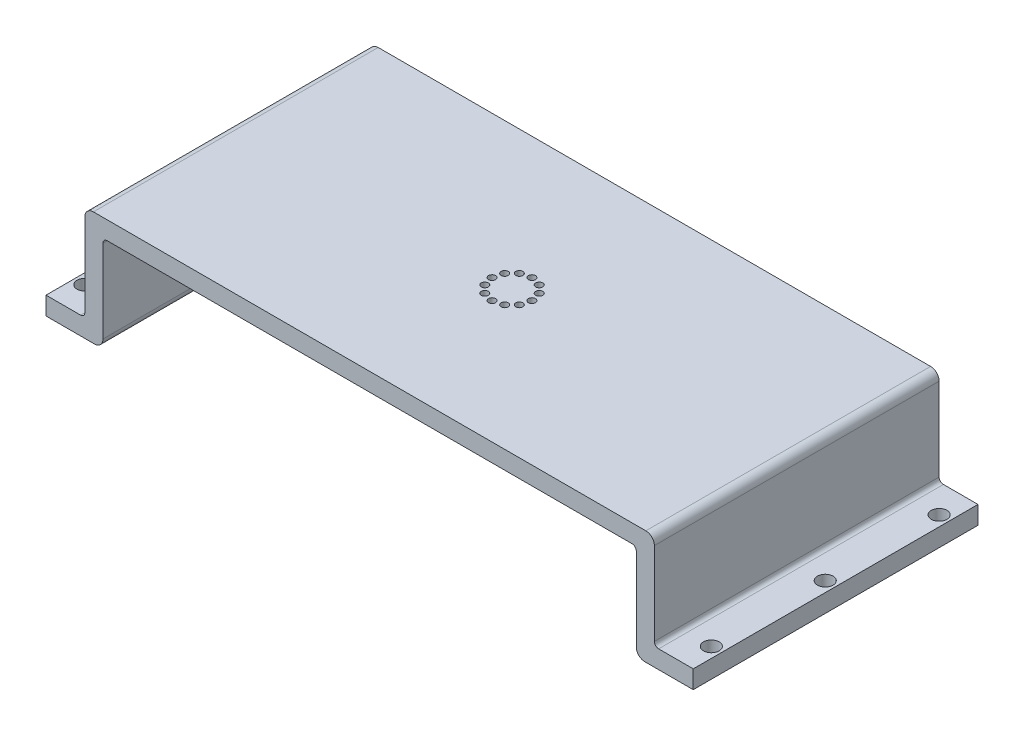
from build123d import *
from OCP.BRepFilletAPI import BRepFilletAPI_MakeFillet

# Parameters (mm, degrees)
BOSS_EXTRUDE1_DEPTH            = 100
FILLET1_R1                     = 3
FILLET1_R2                     = 1.5
F_2_5MM_DOWEL_HOLE1_AT_2_COUNT = 2
F_2_5MM_DOWEL_HOLE1_AT_2_PITCH = 14
CIRPATTERN3_COUNT              = 6
CIRPATTERN3_ANGLE              = 150
F_5_5_5_5_DIAMETER_HOLE1_D     = 5.5


with BuildPart() as part:
    # Sketch1 → Boss-Extrude1 (new body)
    with BuildSketch(Plane.XY):
        Polygon((100, 0), (-100, 0), (-100, -33.65), (-113.65, -33.65), (-113.65, -40), (-93.65, -40), (-93.65, -6.35), (93.65, -6.35), (93.65, -40), (113.65, -40), (113.65, -33.65), (100, -33.65), align=None)
    extrude(amount=BOSS_EXTRUDE1_DEPTH)

    # Fillet1: one fillet with a radius per group of edges: ONE call of the kernel's fillet builder (fillet() takes one radius for all edges)
    fillet1_edges_1 = [part.edges().sort_by_distance(p)[0] for p in [
        (-100, 0, 50),
        (-93.65, -40, 50),
        (100, 0, 50),
        (93.65, -40, 50),
    ]]
    fillet1_edges_2 = [part.edges().sort_by_distance(p)[0] for p in [
        (-93.65, -6.35, 50),
        (93.65, -6.35, 50),
        (100, -33.65, 50),
        (-100, -33.65, 50),
    ]]
    fillet1 = BRepFilletAPI_MakeFillet(part.part.solid().wrapped)
    for e in fillet1_edges_1:
        fillet1.Add(FILLET1_R1, e.wrapped)
    for e in fillet1_edges_2:
        fillet1.Add(FILLET1_R2, e.wrapped)
    add(Compound.cast(fillet1.Shape()), mode=Mode.REPLACE)

    # Sketch2 → Ø2.5mm Dowel Hole1 (revolve, cut)
    with BuildSketch(Plane(origin=(0, -6.35, 57), x_dir=(0, 0, -1), z_dir=(1, 0, 0))):
        Polygon((0, 0), (0, 10.751075774), (1.25, 10), (1.25, 0), align=None)
    f_2_5mm_dowel_hole1 = revolve(axis=Axis((0, -12.7, 57), (0, 1, 0)), mode=Mode.SUBTRACT)

    # Ø2.5mm Dowel Hole1 at 2: Ø2.5mm Dowel Hole1 ×2
    with Locations(*[(0, 0, -i * F_2_5MM_DOWEL_HOLE1_AT_2_PITCH) for i in range(1, F_2_5MM_DOWEL_HOLE1_AT_2_COUNT)]):
        add(f_2_5mm_dowel_hole1, mode=Mode.SUBTRACT)

    # CirPattern3: Ø2.5mm Dowel Hole1 ×6 about axis
    cirpattern3_axis = Axis((0, -6.35, 50), (0, -1, 0))
    for i in range(1, CIRPATTERN3_COUNT):
        add(f_2_5mm_dowel_hole1.rotate(cirpattern3_axis, i * CIRPATTERN3_ANGLE / (CIRPATTERN3_COUNT - 1)), mode=Mode.SUBTRACT)

    # CirPattern3 copy 1 sketch → CirPattern3 copy 1 (revolve, cut)
    with BuildSketch(Plane(origin=(3.5, -6.35, 43.937822174), x_dir=(0.500000000000001, 0, -0.866025403784438), z_dir=(0.866025403784438, 0, 0.500000000000001))):
        Polygon((0, 0), (0, 10.751075774), (1.25, 10), (1.25, 0), align=None)
    revolve(axis=Axis((3.5, -12.7, 43.937822174), (0, 1, 0)), mode=Mode.SUBTRACT)

    # CirPattern3 copy 2 sketch → CirPattern3 copy 2 (revolve, cut)
    with BuildSketch(Plane(origin=(6.062177826, -6.35, 46.5), x_dir=(0.8660254037844398, 0, -0.499999999999998), z_dir=(0.499999999999998, 0, 0.8660254037844398))):
        Polygon((0, 0), (0, 10.751075774), (1.25, 10), (1.25, 0), align=None)
    revolve(axis=Axis((6.062177826, -12.7, 46.5), (0, 1, 0)), mode=Mode.SUBTRACT)

    # CirPattern3 copy 3 sketch → CirPattern3 copy 3 (revolve, cut)
    with BuildSketch(Plane(origin=(7, -6.35, 50), x_dir=(1, 0, 0), z_dir=(0, 0, 1))):
        Polygon((0, 0), (0, 10.751075774), (1.25, 10), (1.25, 0), align=None)
    revolve(axis=Axis((7, -12.7, 50), (0, 1, 0)), mode=Mode.SUBTRACT)

    # CirPattern3 copy 4 sketch → CirPattern3 copy 4 (revolve, cut)
    with BuildSketch(Plane(origin=(6.062177826, -6.35, 53.5), x_dir=(0.8660254037844363, 0, 0.500000000000004), z_dir=(-0.500000000000004, 0, 0.8660254037844363))):
        Polygon((0, 0), (0, 10.751075774), (1.25, 10), (1.25, 0), align=None)
    revolve(axis=Axis((6.062177826, -12.7, 53.5), (0, 1, 0)), mode=Mode.SUBTRACT)

    # CirPattern3 copy 5 sketch → CirPattern3 copy 5 (revolve, cut)
    with BuildSketch(Plane(origin=(3.5, -6.35, 56.062177826), x_dir=(0.49999999999999495, 0, 0.8660254037844416), z_dir=(-0.8660254037844416, 0, 0.49999999999999495))):
        Polygon((0, 0), (0, 10.751075774), (1.25, 10), (1.25, 0), align=None)
    revolve(axis=Axis((3.5, -12.7, 56.062177826), (0, 1, 0)), mode=Mode.SUBTRACT)

    # Ø5.5 (5.5) Diameter Hole1 (through all)
    with Locations(Plane(origin=(0, -33.65, 0), x_dir=(1, 0, 0), z_dir=(0, 1, 0))):
        with Locations((-110, -10), (-110, -50), (-110, -90), (110, -90), (110, -50), (110, -10)):
            Hole(F_5_5_5_5_DIAMETER_HOLE1_D / 2)


solid = part.part
